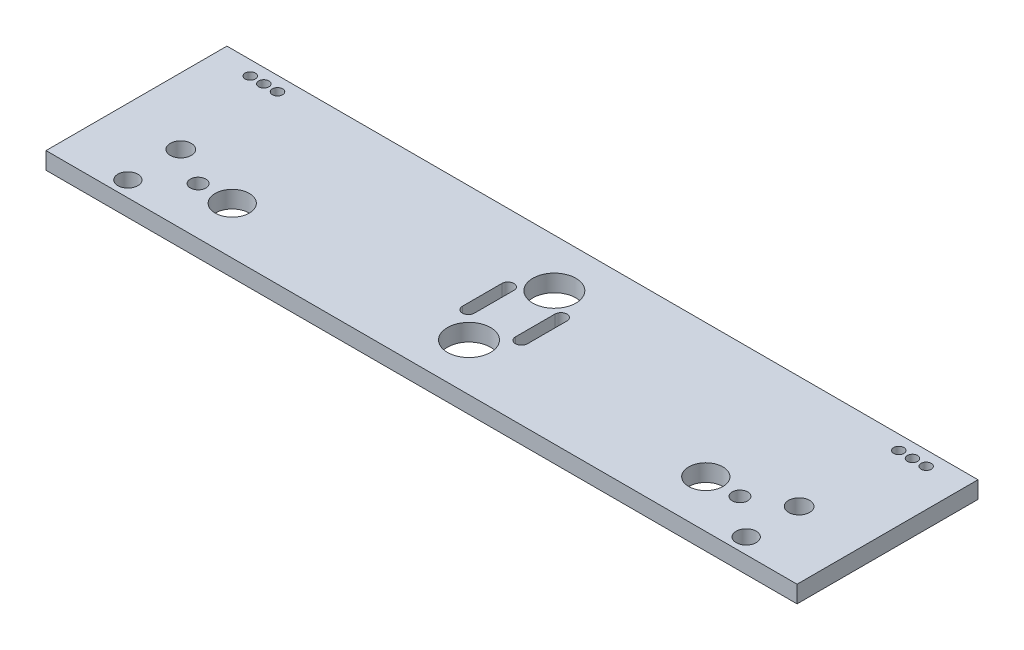
from build123d import *

# Parameters (mm, degrees)
SKETCH1_W           = 220
SKETCH1_H           = 53
SKETCH1_R           = 1.505
SKETCH1_R_2         = 6.315
SKETCH1_R_3         = 3.078429052
SKETCH1_R_4         = 2.929841002
SKETCH1_R_5         = 2.275
SKETCH1_R_6         = 5
BOSS_EXTRUDE1_DEPTH = 5


with BuildPart() as part:
    # Sketch1 → Boss-Extrude1 (new body)
    with BuildSketch(Plane(origin=(0, 0, 0), x_dir=(1, 0, 0), z_dir=(0, 1, 0))):
        with Locations((-42.86437247, 16.587044534)):
            Rectangle(SKETCH1_W, SKETCH1_H)
        with Locations((56.13562753, 38.907044534)):
            Circle(SKETCH1_R, mode=Mode.SUBTRACT)
        with Locations((52.12562753, 38.907044534)):
            Circle(SKETCH1_R, mode=Mode.SUBTRACT)
        with Locations((48.11562753, 38.907044534)):
            Circle(SKETCH1_R, mode=Mode.SUBTRACT)
        with Locations((-141.87437247, 38.907044534)):
            Circle(SKETCH1_R, mode=Mode.SUBTRACT)
        with Locations((-137.87437247, 38.907044534)):
            Circle(SKETCH1_R, mode=Mode.SUBTRACT)
        with Locations((-133.87437247, 38.907044534)):
            Circle(SKETCH1_R, mode=Mode.SUBTRACT)
        with Locations((-42.86437247, 28.997993636)):
            Circle(SKETCH1_R_2, mode=Mode.SUBTRACT)
        with Locations((-42.86437247, 3.997993636)):
            Circle(SKETCH1_R_2, mode=Mode.SUBTRACT)
        with Locations((47.6973107, 10.127310686)):
            Circle(SKETCH1_R_3, mode=Mode.SUBTRACT)
        with Locations((47.6973107, -5.372689314)):
            Circle(SKETCH1_R_4, mode=Mode.SUBTRACT)
        with Locations((36.4973107, 3.997993636)):
            Circle(SKETCH1_R_5, mode=Mode.SUBTRACT)
        with Locations((26.4973107, 3.997993636)):
            Circle(SKETCH1_R_6, mode=Mode.SUBTRACT)
        with Locations((-133.426055639, -5.372689314)):
            Circle(SKETCH1_R_4, mode=Mode.SUBTRACT)
        with Locations((-133.426055639, 10.127310686)):
            Circle(SKETCH1_R_3, mode=Mode.SUBTRACT)
        with Locations((-122.226055639, 3.997993636)):
            Circle(SKETCH1_R_5, mode=Mode.SUBTRACT)
        with Locations((-112.226055639, 3.997993636)):
            Circle(SKETCH1_R_6, mode=Mode.SUBTRACT)
        with BuildLine():
            Line((-52.39437247, 23.161197849), (-52.39437247, 11.591197849))
            ThreePointArc((-52.39437247, 11.591197849), (-50.63437247, 9.831197849), (-48.87437247, 11.591197849))
            Line((-48.87437247, 11.591197849), (-48.87437247, 23.161197849))
            ThreePointArc((-48.87437247, 23.161197849), (-50.63437247, 24.921197849), (-52.39437247, 23.161197849))
        make_face(mode=Mode.SUBTRACT)
        with BuildLine():
            Line((-36.85437247, 23.161197849), (-36.85437247, 11.591197849))
            ThreePointArc((-36.85437247, 11.591197849), (-35.09437247, 9.831197849), (-33.33437247, 11.591197849))
            Line((-33.33437247, 11.591197849), (-33.33437247, 23.161197849))
            ThreePointArc((-33.33437247, 23.161197849), (-35.09437247, 24.921197849), (-36.85437247, 23.161197849))
        make_face(mode=Mode.SUBTRACT)
    extrude(amount=BOSS_EXTRUDE1_DEPTH)


solid = part.part
